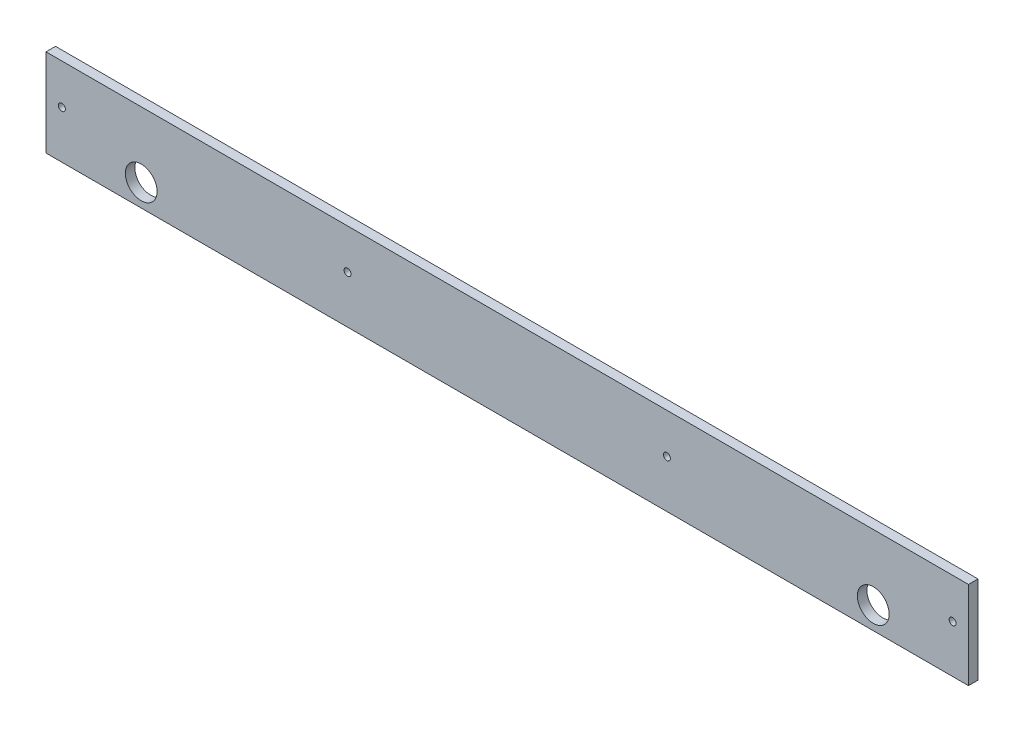
from build123d import *

# Parameters (mm, degrees)
ESQUISSE5_W             = 290.597320494
ESQUISSE5_H             = 27.625
ESQUISSE5_R             = 1.1
EXTRUSION1_DEPTH        = 3
ESQUISSE4_R             = 5
ENL_V_MAT_EXTRU_2_DEPTH = 4


with BuildPart() as part:
    # Esquisse5 → Extrusion1 (new body)
    with BuildSketch(Plane.XY):
        with Locations((141.37166943, 13.8125)):
            Rectangle(ESQUISSE5_W, ESQUISSE5_H)
        with Locations((281.670329677, 15)):
            Circle(ESQUISSE5_R, mode=Mode.SUBTRACT)
        with Locations((91.073009183, 15)):
            Circle(ESQUISSE5_R, mode=Mode.SUBTRACT)
        with Locations((1.073009183, 15)):
            Circle(ESQUISSE5_R, mode=Mode.SUBTRACT)
        with Locations((191.670329678, 15)):
            Circle(ESQUISSE5_R, mode=Mode.SUBTRACT)
    extrude(amount=EXTRUSION1_DEPTH)

    # Esquisse4 → Enlèv. mat.-Extru.2 (cut, through all)
    with BuildSketch(Plane.XY.offset(3)):
        with Locations((26.073009183, 7)):
            Circle(ESQUISSE4_R)
        with Locations((256.670329678, 7)):
            Circle(ESQUISSE4_R)
    extrude(amount=-ENL_V_MAT_EXTRU_2_DEPTH, mode=Mode.SUBTRACT)


solid = part.part
